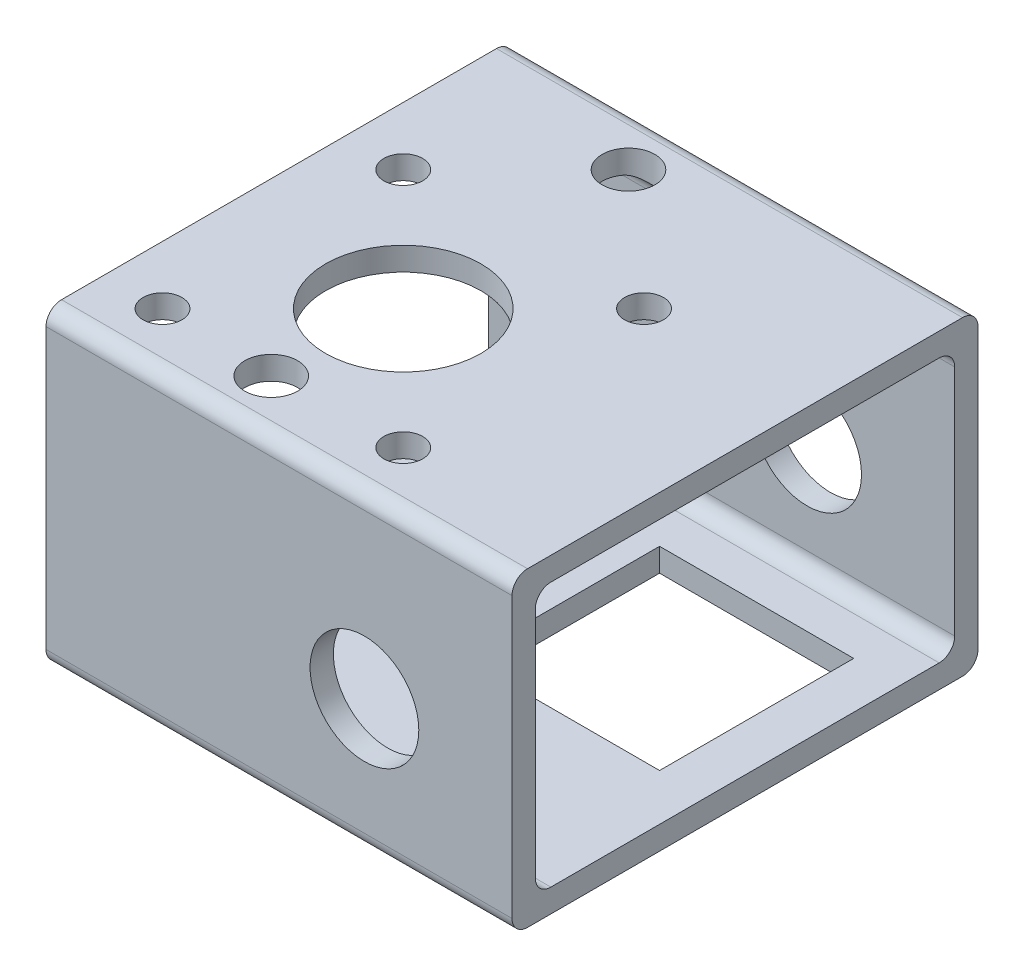
from build123d import *

# Parameters (mm, degrees)
EXTRUDE_1_DEPTH     = 60
CUT_EXTRUDE_1_REACH = 42
SKETCH_2_R          = 2.5
SKETCH_2_R_2        = 10
SKETCH_3_R          = 7
CUT_EXTRUDE_2_DEPTH = 61
HOLE_WIZARD_M8_1_D  = 6.8
CUT_EXTRUDE_3_REACH = 62
SKETCH_6_R          = 2
CUT_EXTRUDE_4_REACH = 42
SKETCH_7_W          = 25
SKETCH_7_H          = 25


with BuildPart() as part:
    # 草图1 → 凸台-拉伸1 (new body)
    with BuildSketch(Plane(origin=(0, 0, 0), x_dir=(0, 0, -1), z_dir=(1, 0, 0))):
        with BuildLine():
            Line((60, 2), (60, 38))
            ThreePointArc((60, 38), (59.414213562, 39.414213562), (58, 40))
            Line((58, 40), (2, 40))
            ThreePointArc((2, 40), (0.585786438, 39.414213562), (0, 38))
            Line((0, 38), (0, 2))
            ThreePointArc((0, 2), (0.585786438, 0.585786438), (2, 0))
            Line((2, 0), (58, 0))
            ThreePointArc((58, 0), (59.414213562, 0.585786438), (60, 2))
        make_face()
        with BuildLine():
            Line((3, 5), (3, 35))
            ThreePointArc((3, 35), (3.585786438, 36.414213562), (5, 37))
            Line((5, 37), (55, 37))
            ThreePointArc((55, 37), (56.414213562, 36.414213562), (57, 35))
            Line((57, 35), (57, 5))
            ThreePointArc((57, 5), (56.414213562, 3.585786438), (55, 3))
            Line((55, 3), (5, 3))
            ThreePointArc((5, 3), (3.585786438, 3.585786438), (3, 5))
        make_face(mode=Mode.SUBTRACT)
    extrude(amount=EXTRUDE_1_DEPTH)

    # 草图2 → 切除-拉伸1 (cut, up to next)
    with BuildSketch(Plane(origin=(0, 40, 0), x_dir=(1, 0, 0), z_dir=(0, 1, 0)), mode=Mode.PRIVATE) as cut_extrude_1_sk1:
        with Locations((7.5, 7.5)):
            Circle(SKETCH_2_R)
    cut_extrude_1_tool1 = extrude(cut_extrude_1_sk1.sketch, amount=-CUT_EXTRUDE_1_REACH, mode=Mode.PRIVATE) & part.part
    add(cut_extrude_1_tool1.solids().sort_by_distance((7.5, 40, -7.5))[0], mode=Mode.SUBTRACT)
    # 草图2 → 切除-拉伸1 (cut, up to next)
    with BuildSketch(Plane(origin=(0, 40, 0), x_dir=(1, 0, 0), z_dir=(0, 1, 0)), mode=Mode.PRIVATE) as cut_extrude_1_sk2:
        with Locations((38.5, 7.5)):
            Circle(SKETCH_2_R)
    cut_extrude_1_tool2 = extrude(cut_extrude_1_sk2.sketch, amount=-CUT_EXTRUDE_1_REACH, mode=Mode.PRIVATE) & part.part
    add(cut_extrude_1_tool2.solids().sort_by_distance((38.5, 40, -7.5))[0], mode=Mode.SUBTRACT)
    # 草图2 → 切除-拉伸1 (cut, up to next)
    with BuildSketch(Plane(origin=(0, 40, 0), x_dir=(1, 0, 0), z_dir=(0, 1, 0)), mode=Mode.PRIVATE) as cut_extrude_1_sk3:
        with Locations((38.5, 38.5)):
            Circle(SKETCH_2_R)
    cut_extrude_1_tool3 = extrude(cut_extrude_1_sk3.sketch, amount=-CUT_EXTRUDE_1_REACH, mode=Mode.PRIVATE) & part.part
    add(cut_extrude_1_tool3.solids().sort_by_distance((38.5, 40, -38.5))[0], mode=Mode.SUBTRACT)
    # 草图2 → 切除-拉伸1 (cut, up to next)
    with BuildSketch(Plane(origin=(0, 40, 0), x_dir=(1, 0, 0), z_dir=(0, 1, 0)), mode=Mode.PRIVATE) as cut_extrude_1_sk4:
        with Locations((7.5, 38.5)):
            Circle(SKETCH_2_R)
    cut_extrude_1_tool4 = extrude(cut_extrude_1_sk4.sketch, amount=-CUT_EXTRUDE_1_REACH, mode=Mode.PRIVATE) & part.part
    add(cut_extrude_1_tool4.solids().sort_by_distance((7.5, 40, -38.5))[0], mode=Mode.SUBTRACT)
    # 草图2 → 切除-拉伸1 (cut, up to next)
    with BuildSketch(Plane(origin=(0, 40, 0), x_dir=(1, 0, 0), z_dir=(0, 1, 0)), mode=Mode.PRIVATE) as cut_extrude_1_sk5:
        with Locations((23, 23)):
            Circle(SKETCH_2_R_2)
    cut_extrude_1_tool5 = extrude(cut_extrude_1_sk5.sketch, amount=-CUT_EXTRUDE_1_REACH, mode=Mode.PRIVATE) & part.part
    add(cut_extrude_1_tool5.solids().sort_by_distance((23, 40, -23))[0], mode=Mode.SUBTRACT)

    # 草图3 → 切除-拉伸2 (cut, through all)
    with BuildSketch(Plane.XY):
        with Locations((41, 17)):
            Circle(SKETCH_3_R)
    extrude(amount=-CUT_EXTRUDE_2_DEPTH, mode=Mode.SUBTRACT)

    # M8 螺纹孔1 (through all)
    with Locations(Plane(origin=(0, 40, 0), x_dir=(1, 0, 0), z_dir=(0, 1, 0))):
        with Locations((22, 53), (22, 7)):
            Hole(HOLE_WIZARD_M8_1_D / 2)

    # 草图6 → 切除-拉伸3 (cut, up to next)
    with BuildSketch(Plane(origin=(0, 0, -60), x_dir=(-1, 0, 0), z_dir=(0, 0, -1)), mode=Mode.PRIVATE) as cut_extrude_3_sk1:
        with Locations((-9.514718626, 11.514718626)):
            Circle(SKETCH_6_R)
    cut_extrude_3_tool1 = extrude(cut_extrude_3_sk1.sketch, amount=-CUT_EXTRUDE_3_REACH, mode=Mode.PRIVATE) & part.part
    add(cut_extrude_3_tool1.solids().sort_by_distance((9.514719, 11.514719, -60))[0], mode=Mode.SUBTRACT)
    # 草图6 → 切除-拉伸3 (cut, up to next)
    with BuildSketch(Plane(origin=(0, 0, -60), x_dir=(-1, 0, 0), z_dir=(0, 0, -1)), mode=Mode.PRIVATE) as cut_extrude_3_sk2:
        with Locations((-26.485281374, 11.514718626)):
            Circle(SKETCH_6_R)
    cut_extrude_3_tool2 = extrude(cut_extrude_3_sk2.sketch, amount=-CUT_EXTRUDE_3_REACH, mode=Mode.PRIVATE) & part.part
    add(cut_extrude_3_tool2.solids().sort_by_distance((26.485281, 11.514719, -60))[0], mode=Mode.SUBTRACT)
    # 草图6 → 切除-拉伸3 (cut, up to next)
    with BuildSketch(Plane(origin=(0, 0, -60), x_dir=(-1, 0, 0), z_dir=(0, 0, -1)), mode=Mode.PRIVATE) as cut_extrude_3_sk3:
        with Locations((-26.485281374, 28.485281374)):
            Circle(SKETCH_6_R)
    cut_extrude_3_tool3 = extrude(cut_extrude_3_sk3.sketch, amount=-CUT_EXTRUDE_3_REACH, mode=Mode.PRIVATE) & part.part
    add(cut_extrude_3_tool3.solids().sort_by_distance((26.485281, 28.485281, -60))[0], mode=Mode.SUBTRACT)
    # 草图6 → 切除-拉伸3 (cut, up to next)
    with BuildSketch(Plane(origin=(0, 0, -60), x_dir=(-1, 0, 0), z_dir=(0, 0, -1)), mode=Mode.PRIVATE) as cut_extrude_3_sk4:
        with Locations((-9.514718626, 28.485281374)):
            Circle(SKETCH_6_R)
    cut_extrude_3_tool4 = extrude(cut_extrude_3_sk4.sketch, amount=-CUT_EXTRUDE_3_REACH, mode=Mode.PRIVATE) & part.part
    add(cut_extrude_3_tool4.solids().sort_by_distance((9.514719, 28.485281, -60))[0], mode=Mode.SUBTRACT)

    # 草图7 → 切除-拉伸4 (cut, up to next)
    with BuildSketch(Plane.XZ, mode=Mode.PRIVATE) as cut_extrude_4_sk1:
        with Locations((41.5, -37.5)):
            Rectangle(SKETCH_7_W, SKETCH_7_H)
    cut_extrude_4_tool1 = extrude(cut_extrude_4_sk1.sketch, amount=-CUT_EXTRUDE_4_REACH, mode=Mode.PRIVATE) & part.part
    add(cut_extrude_4_tool1.solids().sort_by_distance((41.5, 0, -37.5))[0], mode=Mode.SUBTRACT)


solid = part.part
